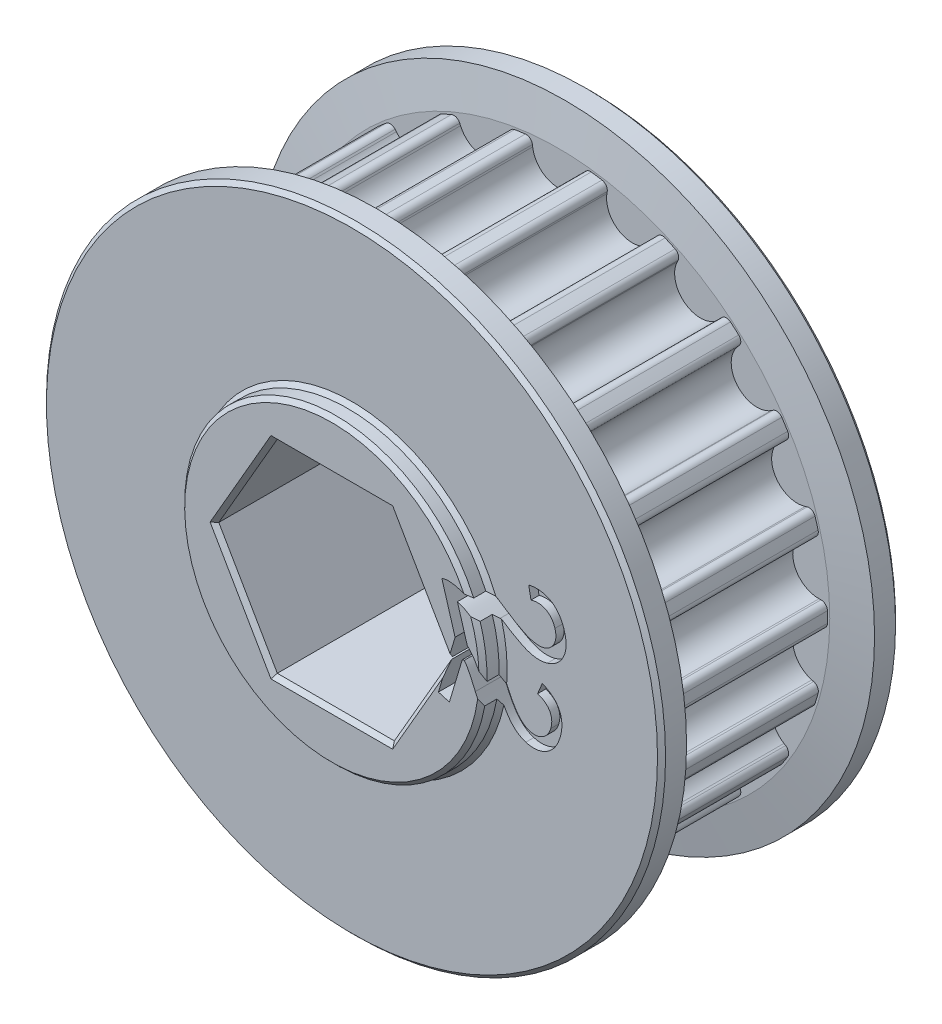
from build123d import *

# Parameters (mm, degrees)
SKETCH2_R                                 = 16.966685058
PULLEY_DEPTH                              = 5.500000049
CUT_TOOTH_DEPTH                           = 5.500000049
BLEND_TOOTH_R                             = 0.4
TOOTH_PATTERN_COUNT                       = 22
BLEND_TOOTH_OF_TOOTH_PATTERN_R            = 0.4
SIDEWALL_START                            = 5.500000049
SKETCH3_R                                 = 19.506685058
SIDEWALL_DEPTH                            = 2.000000064
SIDEWALL_CHAMFER_SIZE                     = 2.400000026
SIDEWALL_CHAMFER_SIZE2                    = 0.423184758
SIDEWALL_CHAMFER_PART_2_SIZE              = 2.400000026
SIDEWALL_CHAMFER_PART_2_SIZE2             = 0.423184758
SKETCH5_R                                 = 9.525
BEARING_SPACER_MANUAL_SUPPRESS_DEPTH      = 8.770000113
BEARING_SPACER_MANUAL_SUPPRESS_DEPTH_BACK = 8.770000113
HEX_SHAFT_DEPTH                           = 63.5
CHAMFERS_SIZE                             = 0.254
CUT_EXTRUDE_START                         = 6.992000113
CUT_EXTRUDE_4419_DEPTH                    = 2.54


with BuildPart() as part:
    # Sketch2 → pulley (new body, symmetric)
    with BuildSketch(Plane.XY):
        Circle(SKETCH2_R)
    extrude(amount=PULLEY_DEPTH, both=True)

    # tooth → cut tooth (cut, symmetric)
    with BuildSketch(Plane.XY):
        with BuildLine():
            Line((-2.132711961, 20.602277505), (-1.612887548, 16.368647407))
            ThreePointArc((-1.612887548, 16.368647407), (0, 14.941685044), (1.612887548, 16.368647407))
            Line((1.612887548, 16.368647407), (2.132711961, 20.602277505))
            Line((2.132711961, 20.602277505), (-2.132711961, 20.602277505))
        make_face()
    cut_tooth = extrude(amount=CUT_TOOTH_DEPTH, both=True, mode=Mode.SUBTRACT)

    # blend tooth
    blend_tooth_edges = [part.edges().sort_by_distance(p)[0] for p in [
        (1.676126872, 16.883690372, 0),
        (-1.676126872, 16.883690372, 0),
    ]]
    fillet(blend_tooth_edges, radius=BLEND_TOOTH_R)

    # tooth pattern: cut tooth ×22 about axis
    tooth_pattern_axis = Axis((0, 0, 0), (0, 0, 1))
    for i in range(1, TOOTH_PATTERN_COUNT):
        add(cut_tooth.rotate(tooth_pattern_axis, i * 360 / TOOTH_PATTERN_COUNT), mode=Mode.SUBTRACT)

    # blend tooth of tooth pattern
    blend_tooth_of_tooth_pattern_edges = [part.edges().sort_by_distance(p)[0] for p in [
        (-3.1484533, 16.67200179, 0),
        (-6.364917214, 15.727562771, 0),
        (-7.717964511, 15.109646775, 0),
        (-10.538059817, 13.29728157, 0),
        (-11.662212138, 12.323198039, 0),
        (-13.857471486, 9.789733698, 0),
        (-14.661656695, 8.538397087, 0),
        (-16.054233228, 5.489079824, 0),
        (-16.473301023, 4.061865982, 0),
        (-16.950376473, 0.743733347, 0),
        (-16.950376473, -0.743733347, 0),
        (-16.473301023, -4.061865982, 0),
        (-16.054233228, -5.489079824, 0),
        (-14.661656695, -8.538397087, 0),
        (-13.857471486, -9.789733698, 0),
        (-11.662212138, -12.323198039, 0),
        (-10.538059817, -13.29728157, 0),
        (-7.717964511, -15.109646775, 0),
        (-6.364917214, -15.727562771, 0),
        (-3.1484533, -16.67200179, 0),
        (-1.676126872, -16.883690372, 0),
        (1.676126872, -16.883690372, 0),
        (3.1484533, -16.67200179, 0),
        (6.364917214, -15.727562771, 0),
        (7.717964511, -15.109646775, 0),
        (10.538059817, -13.29728157, 0),
        (11.662212138, -12.323198039, 0),
        (13.857471486, -9.789733698, 0),
        (14.661656695, -8.538397087, 0),
        (16.054233228, -5.489079824, 0),
        (16.473301023, -4.061865982, 0),
        (16.950376473, -0.743733347, 0),
        (16.950376473, 0.743733347, 0),
        (16.473301023, 4.061865982, 0),
        (16.054233228, 5.489079824, 0),
        (14.661656695, 8.538397087, 0),
        (13.857471486, 9.789733698, 0),
        (11.662212138, 12.323198039, 0),
        (10.538059817, 13.29728157, 0),
        (7.717964511, 15.109646775, 0),
        (6.364917214, 15.727562771, 0),
        (3.1484533, 16.67200179, 0),
    ]]
    fillet(blend_tooth_of_tooth_pattern_edges, radius=BLEND_TOOTH_OF_TOOTH_PATTERN_R)

    # Sketch3 → sidewall (add)
    with BuildSketch(Plane.XY.offset(SIDEWALL_START)):
        Circle(SKETCH3_R)
    sidewall = extrude(amount=SIDEWALL_DEPTH)

    # mirror sidewall: sidewall across plane
    add(sidewall.mirror(Plane.XY))

    # sidewall chamfer
    sidewall_chamfer_edges = [part.edges().sort_by_distance(p)[0] for p in [
        (-19.506685058, 0, 5.500000049),
    ]]
    sidewall_chamfer_side = [part.faces().sort_by_distance(p)[0] for p in [
        (-18.954952687, 0, 5.500000049),
    ]]
    chamfer(sidewall_chamfer_edges, length=SIDEWALL_CHAMFER_SIZE, length2=SIDEWALL_CHAMFER_SIZE2, reference=sidewall_chamfer_side[0])

    # sidewall chamfer part 2
    sidewall_chamfer_part_2_edges = [part.edges().sort_by_distance(p)[0] for p in [
        (-19.506685058, 0, -5.500000049),
    ]]
    sidewall_chamfer_part_2_side = [part.faces().sort_by_distance(p)[0] for p in [
        (-18.954952687, 0, -5.500000049),
    ]]
    chamfer(sidewall_chamfer_part_2_edges, length=SIDEWALL_CHAMFER_PART_2_SIZE, length2=SIDEWALL_CHAMFER_PART_2_SIZE2, reference=sidewall_chamfer_part_2_side[0])

    # Sketch5 → bearing spacer (Manual Suppress) (add, two sides)
    with BuildSketch(Plane.XY) as bearing_spacer_manual_suppress_sk:
        Circle(SKETCH5_R)
    extrude(amount=BEARING_SPACER_MANUAL_SUPPRESS_DEPTH)
    extrude(bearing_spacer_manual_suppress_sk.sketch, amount=-BEARING_SPACER_MANUAL_SUPPRESS_DEPTH_BACK)

    # Sketch4 → hex shaft (cut, symmetric)
    with BuildSketch(Plane.XY):
        Polygon((3.688171255, 6.3881), (-3.688171255, 6.3881), (-7.376342509, 0), (-3.688171255, -6.3881), (3.688171255, -6.3881), (7.376342509, 0), align=None)
    extrude(amount=HEX_SHAFT_DEPTH, both=True, mode=Mode.SUBTRACT)

    # chamfers
    chamfers_edges = [part.edges().sort_by_distance(p)[0] for p in [
        (-19.506685058, 0, 7.500000113),
        (-19.506685058, 0, -7.500000113),
        (-9.525, 0, -7.500000113),
        (-9.525, 0, 7.500000113),
        (-9.525, 0, -8.770000113),
        (-9.525, 0, 8.770000113),
        (0, 6.3881, 8.770000113),
        (-5.532256882, 3.19405, 8.770000113),
        (-5.532256882, -3.19405, 8.770000113),
        (0, -6.3881, 8.770000113),
        (5.532256882, -3.19405, 8.770000113),
        (5.532256882, 3.19405, 8.770000113),
        (5.532256882, 3.19405, -8.770000113),
        (5.532256882, -3.19405, -8.770000113),
        (0, -6.3881, -8.770000113),
        (-5.532256882, -3.19405, -8.770000113),
        (-5.532256882, 3.19405, -8.770000113),
        (0, 6.3881, -8.770000113),
    ]]
    chamfer(chamfers_edges, length=CHAMFERS_SIZE)

    # Sketch6 → 4419 (cut)
    with BuildSketch(Plane.XY.offset(CUT_EXTRUDE_START)):
        with BuildLine():
            Line((8.766198019, 0.589858789), (8.07843191, 0.384887202))
            Line((8.07843191, 0.384887202), (6.931331882, 4.236130461))
            add(Edge.make_bspline(
                [(6.931331882, 4.236130461), (6.973928693, 4.24890387), (7.058624263, 4.274301337), (7.188956622, 4.297427056), (7.320577394, 4.308171263), (7.408360376, 4.303777636), (7.45240423, 4.301573196)],
                knots=[0, 0, 0, 0, 0.000133315, 0.000265071, 0.000396329, 0.000528501, 0.000528501, 0.000528501, 0.000528501], degree=3))
            add(Edge.make_bspline(
                [(7.45240423, 4.301573196), (7.526313154, 4.294486229), (7.677039723, 4.280033383), (7.903958115, 4.228030061), (8.136041701, 4.156614255), (8.331820725, 4.078466956), (8.492790819, 4.003004587), (8.622180148, 3.939004595), (8.75826156, 3.867338495), (8.900297464, 3.787001851), (9.047747953, 3.697658951), (9.203000258, 3.602533506), (9.364552461, 3.499056292), (9.473462339, 3.42553063), (9.529285013, 3.387844434)],
                knots=[0, 0, 0, 0, 0.000222539, 0.000453837, 0.00069677, 0.000950595, 0.001085389, 0.001230067, 0.001383616, 0.001546727, 0.001719524, 0.001900804, 0.002092956, 0.00229501, 0.00229501, 0.00229501, 0.00229501], degree=3))
            add(Edge.make_bspline(
                [(9.529285013, 3.387844434), (9.614599201, 3.330180573), (9.779190501, 3.218933311), (10.021913289, 3.065421957), (10.246942179, 2.92510911), (10.457204794, 2.802876813), (10.650966346, 2.696343509), (10.828965964, 2.60545543), (10.991676244, 2.531230748), (11.140639732, 2.471548378), (11.279552066, 2.426926064), (11.411296301, 2.391574377), (11.538778274, 2.366647366), (11.66174668, 2.35191917), (11.779907198, 2.345980544), (11.892998473, 2.353150256), (12.001997275, 2.366625033), (12.071824867, 2.384864422), (12.106247078, 2.393855712)],
                knots=[0, 0, 0, 0, 0.000308902, 0.000595945, 0.000861515, 0.001104426, 0.001325463, 0.001524812, 0.00170385, 0.001861832, 0.00200592, 0.002141295, 0.002270851, 0.002395214, 0.002512621, 0.002625154, 0.00273482, 0.00284144, 0.00284144, 0.00284144, 0.00284144], degree=3))
            add(Edge.make_bspline(
                [(12.106247078, 2.393855712), (12.140684562, 2.405081651), (12.208770866, 2.427276441), (12.304725448, 2.472435455), (12.395111251, 2.523818193), (12.475818005, 2.586386619), (12.551665896, 2.654794725), (12.619040235, 2.732719127), (12.679957702, 2.818868355), (12.733993812, 2.911537215), (12.778236064, 3.010586839), (12.813330509, 3.113355771), (12.836638251, 3.219819436), (12.849021003, 3.329044779), (12.850221664, 3.441173362), (12.839657799, 3.555922962), (12.820404698, 3.674251321), (12.79886897, 3.752680602), (12.787839344, 3.792848534)],
                knots=[0, 0, 0, 0, 0.000108561, 0.000214637, 0.00031756, 0.0004198, 0.000520303, 0.000623567, 0.000728064, 0.000836499, 0.000944821, 0.001052981, 0.001161732, 0.001271091, 0.001382227, 0.001497485, 0.00161644, 0.001741323, 0.001741323, 0.001741323, 0.001741323], degree=3))
            add(Edge.make_bspline(
                [(12.787839344, 3.792848534), (12.774641239, 3.834707149), (12.748855912, 3.91648693), (12.69767548, 4.031579691), (12.63886556, 4.137355115), (12.574592323, 4.235529839), (12.499113341, 4.322173155), (12.417846455, 4.400663876), (12.327901181, 4.468667308), (12.232005618, 4.528332076), (12.129060371, 4.57624541), (12.02124193, 4.613954076), (11.908366485, 4.637999366), (11.790969182, 4.652234147), (11.668938301, 4.652592231), (11.542456361, 4.643003051), (11.411643971, 4.620117688), (11.324076942, 4.597318695), (11.278952117, 4.585569974)],
                knots=[0, 0, 0, 0, 0.000131588, 0.000257086, 0.000377018, 0.000494483, 0.000608323, 0.000720985, 0.000832859, 0.000945947, 0.001059183, 0.001172815, 0.001287861, 0.001404721, 0.001526969, 0.001653303, 0.001784844, 0.001924701, 0.001924701, 0.001924701, 0.001924701], degree=3))
            Line((11.278952117, 4.585569974), (11.135718959, 5.342483125))
            add(Edge.make_bspline(
                [(11.135718959, 5.342483125), (11.204697722, 5.355186393), (11.339127766, 5.379943302), (11.538736352, 5.396524061), (11.729960118, 5.39867513), (11.912855296, 5.383007101), (12.087326445, 5.349247288), (12.253591184, 5.299632235), (12.412369273, 5.234748757), (12.561350204, 5.150876668), (12.700661422, 5.052211173), (12.830182114, 4.938850446), (12.949164328, 4.81088582), (13.057992973, 4.668044387), (13.157177671, 4.510811286), (13.244344348, 4.337988601), (13.322811474, 4.151716772), (13.364286535, 4.020420081), (13.385467346, 3.953368452)],
                knots=[0, 0, 0, 0, 0.000210303, 0.00040985, 0.000600009, 0.000783458, 0.000959511, 0.001132185, 0.001303248, 0.001472951, 0.001643908, 0.001814543, 0.0019884, 0.002167203, 0.002352537, 0.002545264, 0.002747291, 0.002958144, 0.002958144, 0.002958144, 0.002958144], degree=3))
            add(Edge.make_bspline(
                [(13.385467346, 3.953368452), (13.404265986, 3.884891979), (13.441005143, 3.751064855), (13.476358108, 3.550659046), (13.495889354, 3.35704857), (13.496271151, 3.169608742), (13.477180998, 2.989025672), (13.443208993, 2.814532451), (13.389775385, 2.646712437), (13.317720069, 2.487377523), (13.233381012, 2.336762539), (13.135292329, 2.199251962), (13.026285302, 2.074872672), (12.905455129, 1.964383391), (12.773662348, 1.866077306), (12.63035296, 1.780698287), (12.474428963, 1.709645407), (12.364701808, 1.673761971), (12.308749128, 1.65546409)],
                knots=[0, 0, 0, 0, 0.000212932, 0.000416145, 0.000609657, 0.000796107, 0.000977332, 0.001153623, 0.001328569, 0.00150434, 0.001677406, 0.001845634, 0.002010113, 0.002172662, 0.002335899, 0.002502557, 0.002672192, 0.0028487, 0.0028487, 0.0028487, 0.0028487], degree=3))
            add(Edge.make_bspline(
                [(12.308749128, 1.65546409), (12.250170793, 1.639717555), (12.132957395, 1.608209236), (11.950953691, 1.584958513), (11.765745382, 1.576532367), (11.575068717, 1.59005538), (11.376703949, 1.621993285), (11.169095403, 1.679449415), (10.94957845, 1.756456674), (10.759281475, 1.838587313), (10.595601297, 1.917476032), (10.459121288, 1.991496161), (10.308495548, 2.073216535), (10.145936708, 2.168311674), (9.970664749, 2.273807955), (9.781908866, 2.390343287), (9.581553115, 2.518747191), (9.443630046, 2.608225861), (9.372469401, 2.654391886)],
                knots=[0, 0, 0, 0, 0.000181784, 0.000363744, 0.000549107, 0.000737198, 0.000936133, 0.001150887, 0.001382461, 0.001633606, 0.001772219, 0.001927437, 0.002099301, 0.002286306, 0.002492349, 0.002713024, 0.002951769, 0.003206243, 0.003206243, 0.003206243, 0.003206243], degree=3))
            add(Edge.make_bspline(
                [(9.372469401, 2.654391886), (9.314068403, 2.692737903), (9.202415741, 2.766048891), (9.041956723, 2.869875539), (8.896397841, 2.962064836), (8.766456958, 3.044427115), (8.651375157, 3.114023657), (8.551373165, 3.172922471), (8.467040862, 3.220794372), (8.336908311, 3.290716169), (8.156892649, 3.373554883), (7.993003421, 3.424063994), (7.914207686, 3.448348095)],
                knots=[0, 0, 0, 0, 0.000209594, 0.000400709, 0.000573351, 0.000726487, 0.000862228, 0.000976795, 0.001074662, 0.001153106, 0.001420028, 0.001667194, 0.001667194, 0.001667194, 0.001667194], degree=3))
            Line((7.914207686, 3.448348095), (8.766198019, 0.589858789))
        make_face()
        with BuildLine():
            Line((7.407169085, -2.286511012), (6.719402976, -2.081539424))
            Line((6.719402976, -2.081539424), (7.866503004, 1.769703835))
            add(Edge.make_bspline(
                [(7.866503004, 1.769703835), (7.909217887, 1.757460164), (7.994158328, 1.733113083), (8.115593811, 1.680207001), (8.231155159, 1.616233341), (8.302449801, 1.564654713), (8.338184608, 1.538802107)],
                knots=[0, 0, 0, 0, 0.000133178, 0.00026483, 0.000396395, 0.000528607, 0.000528607, 0.000528607, 0.000528607], degree=3))
            add(Edge.make_bspline(
                [(8.338184608, 1.538802107), (8.396359568, 1.492152303), (8.514746862, 1.397218949), (8.677773819, 1.230941063), (8.832285204, 1.043306882), (8.953871375, 0.870717508), (9.047455386, 0.7193148), (9.120992159, 0.595357994), (9.194828386, 0.460557062), (9.269782042, 0.315644448), (9.345106173, 0.160042871), (9.423093757, -0.004558488), (9.500567471, -0.180263357), (9.551703308, -0.300938395), (9.577892281, -0.362741535)],
                knots=[0, 0, 0, 0, 0.000223548, 0.000454924, 0.00069697, 0.000952189, 0.001087524, 0.00123089, 0.001384523, 0.001548543, 0.001720287, 0.00190312, 0.002094939, 0.002296309, 0.002296309, 0.002296309, 0.002296309], degree=3))
            add(Edge.make_bspline(
                [(9.577892281, -0.362741535), (9.61784845, -0.457571474), (9.694932666, -0.640519234), (9.812609392, -0.90259532), (9.925471349, -1.142773411), (10.034403346, -1.360431915), (10.137440817, -1.556241461), (10.238036568, -1.729068187), (10.331666572, -1.881529329), (10.424877827, -2.012044988), (10.515679253, -2.126117293), (10.607879407, -2.226560871), (10.700134396, -2.316995727), (10.794174829, -2.396934611), (10.891027415, -2.46456364), (10.988088479, -2.523452071), (11.087771028, -2.569507083), (11.155707826, -2.592492743), (11.189265302, -2.603846541)],
                knots=[0, 0, 0, 0, 0.000308702, 0.000595554, 0.000861786, 0.001104757, 0.001325708, 0.001525424, 0.001704606, 0.001862212, 0.002006262, 0.002141732, 0.002270965, 0.002393649, 0.002511497, 0.002625001, 0.002733836, 0.00284007, 0.00284007, 0.00284007, 0.00284007], degree=3))
            add(Edge.make_bspline(
                [(11.189265302, -2.603846541), (11.224104584, -2.613143302), (11.293159494, -2.631570403), (11.397820986, -2.64743261), (11.501698626, -2.652739891), (11.603861689, -2.646181869), (11.704950115, -2.630386769), (11.804248757, -2.602816404), (11.902352458, -2.564357454), (11.997658074, -2.514566849), (12.090627429, -2.458111504), (12.174212539, -2.388548173), (12.253068831, -2.313984392), (12.322032842, -2.228415646), (12.385840733, -2.136265246), (12.439055883, -2.033862587), (12.488980718, -1.924998229), (12.512983427, -1.84726132), (12.525284926, -1.807420795)],
                knots=[0, 0, 0, 0, 0.000108111, 0.000214287, 0.000316892, 0.000419563, 0.000520859, 0.000623308, 0.000728096, 0.000836334, 0.000945623, 0.001053614, 0.001161894, 0.001270666, 0.001382656, 0.001497563, 0.001616415, 0.001741365, 0.001741365, 0.001741365, 0.001741365], degree=3))
            add(Edge.make_bspline(
                [(12.525284926, -1.807420795), (12.537165148, -1.765215479), (12.560362673, -1.682804658), (12.581598262, -1.558277422), (12.589403785, -1.437574697), (12.589835072, -1.320004197), (12.573779489, -1.206840775), (12.549580042, -1.09652251), (12.512387683, -0.989927491), (12.462335892, -0.887959945), (12.404251019, -0.789806754), (12.332230835, -0.701115486), (12.253277998, -0.617211367), (12.162672566, -0.5415285), (12.060258379, -0.475354683), (11.949039604, -0.414593343), (11.827595901, -0.361195744), (11.741876439, -0.332818426), (11.697989965, -0.318289866)],
                knots=[0, 0, 0, 0, 0.000131478, 0.000256727, 0.000378042, 0.000494117, 0.000608678, 0.000720109, 0.000832574, 0.000946341, 0.001060482, 0.001173872, 0.00128828, 0.001405745, 0.001526979, 0.001653511, 0.001785655, 0.001924285, 0.001924285, 0.001924285, 0.001924285], degree=3))
            Line((11.697989965, -0.318289866), (11.991864891, 0.394171616))
            add(Edge.make_bspline(
                [(11.991864891, 0.394171616), (12.056553011, 0.366794106), (12.182319216, 0.313566936), (12.358795416, 0.218497669), (12.520047471, 0.115745162), (12.663721198, 0.000800294), (12.7935099, -0.120849473), (12.904817739, -0.254120691), (13.001106702, -0.395673614), (13.079740186, -0.546808951), (13.143540407, -0.705422096), (13.188645623, -0.871721336), (13.218841523, -1.044061851), (13.230540912, -1.223206122), (13.226608745, -1.408665803), (13.206624998, -1.600715475), (13.169538082, -1.799398763), (13.132201968, -1.931981092), (13.113034779, -2.000044697)],
                knots=[0, 0, 0, 0, 0.000210625, 0.000409495, 0.00060061, 0.000783422, 0.000960718, 0.00113336, 0.001303225, 0.001473337, 0.001643471, 0.001815121, 0.001989294, 0.002167529, 0.002352781, 0.002545187, 0.002746193, 0.002958242, 0.002958242, 0.002958242, 0.002958242], degree=3))
            add(Edge.make_bspline(
                [(13.113034779, -2.000044697), (13.091470039, -2.067925179), (13.04945931, -2.200164588), (12.969896738, -2.387854522), (12.87848012, -2.559407463), (12.777076378, -2.716850016), (12.662900716, -2.858069009), (12.537642585, -2.984739753), (12.401504221, -3.096774614), (12.254489089, -3.190942456), (12.10168068, -3.270378244), (11.944695652, -3.331872005), (11.785288911, -3.377727432), (11.623089216, -3.402660998), (11.458943666, -3.413159709), (11.292098763, -3.40555848), (11.122954918, -3.379531391), (11.011225675, -3.349854434), (10.954659269, -3.334829552)],
                knots=[0, 0, 0, 0, 0.000213586, 0.000416092, 0.000610532, 0.000796158, 0.000977043, 0.001154287, 0.00132978, 0.001504795, 0.001677098, 0.001845629, 0.002009811, 0.002173631, 0.00233692, 0.002502544, 0.002673684, 0.002849177, 0.002849177, 0.002849177, 0.002849177], degree=3))
            add(Edge.make_bspline(
                [(10.954659269, -3.334829552), (10.897012754, -3.315380743), (10.781935433, -3.276555902), (10.616217441, -3.197607766), (10.458497021, -3.100665638), (10.305035951, -2.987285744), (10.158493877, -2.850015493), (10.013811748, -2.69063147), (9.873501966, -2.504845596), (9.758520497, -2.332544538), (9.664260729, -2.177255097), (9.5898438, -2.041035655), (9.509183804, -1.889547494), (9.426010086, -1.72077923), (9.335259028, -1.537485949), (9.241759032, -1.336655971), (9.142879397, -1.119961558), (9.077168864, -0.96911575), (9.043237478, -0.891222495)],
                knots=[0, 0, 0, 0, 0.000182399, 0.000364116, 0.000549199, 0.000737132, 0.000935484, 0.001150525, 0.001382179, 0.001633204, 0.001771697, 0.001927008, 0.002098787, 0.002286537, 0.002491412, 0.002712363, 0.002951079, 0.003205963, 0.003205963, 0.003205963, 0.003205963], degree=3))
            add(Edge.make_bspline(
                [(9.043237478, -0.891222495), (9.015239548, -0.827019597), (8.961900266, -0.704705683), (8.885594584, -0.52929544), (8.813444337, -0.372865949), (8.751659605, -0.232214715), (8.692724769, -0.111589924), (8.642538366, -0.007452829), (8.598317877, 0.079152026), (8.526664865, 0.208142898), (8.421919523, 0.376625846), (8.312081911, 0.508458192), (8.259159418, 0.571978294)],
                knots=[0, 0, 0, 0, 0.000210128, 0.000400319, 0.000573838, 0.000726919, 0.000861123, 0.00097654, 0.001073734, 0.001152769, 0.001419262, 0.00166706, 0.00166706, 0.00166706, 0.00166706], degree=3))
            Line((8.259159418, 0.571978294), (7.407169085, -2.286511012))
        make_face()
    extrude(amount=CUT_EXTRUDE_4419_DEPTH, mode=Mode.SUBTRACT)


solid = part.part
